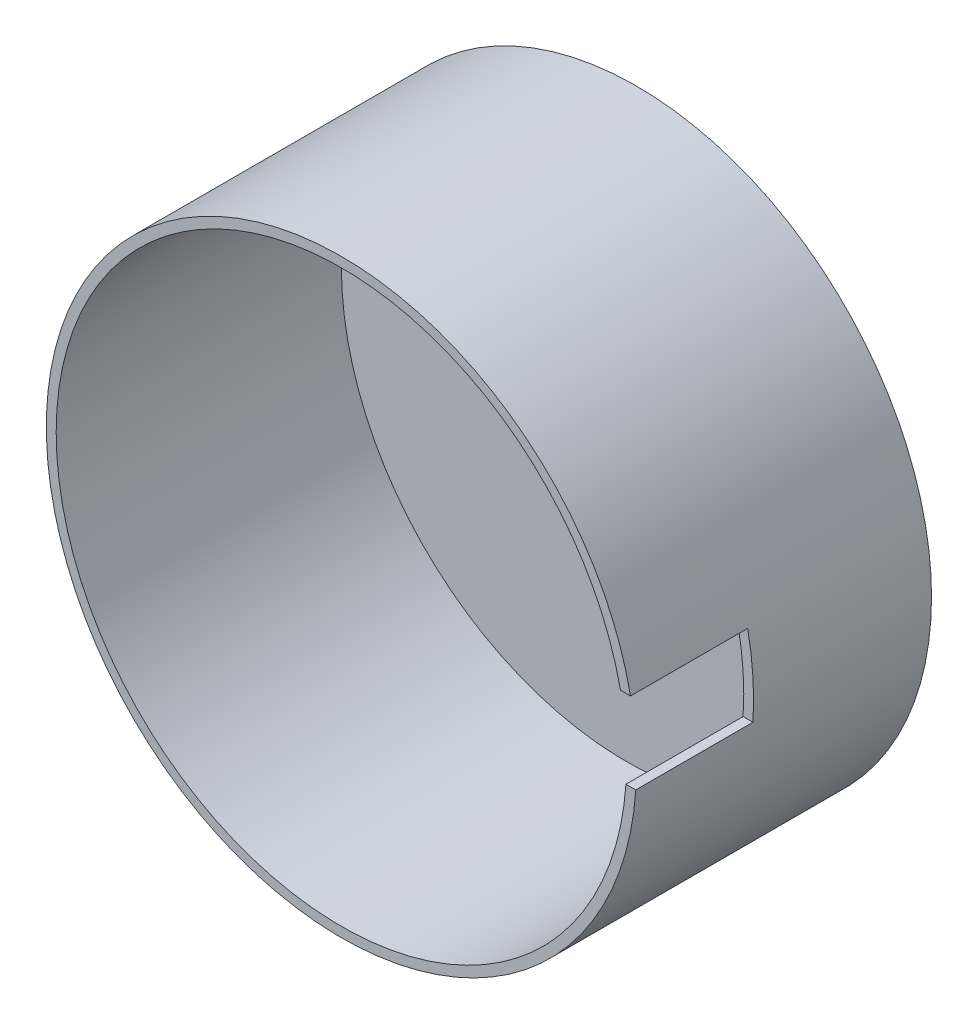
from build123d import *

# Parameters (mm, degrees)
SKETCH1_R           = 150
BOSS_EXTRUDE1_DEPTH = 150
SHELL2_T            = -5
SKETCH4_W           = 60
SKETCH4_H           = 40
CUT_EXTRUDE1_DEPTH  = 150


with BuildPart() as part:
    # Sketch1 → Boss-Extrude1 (new body)
    with BuildSketch(Plane.XY):
        Circle(SKETCH1_R)
    extrude(amount=BOSS_EXTRUDE1_DEPTH)

    # Shell2
    shell2_openings = [part.faces().sort_by_distance(p)[0] for p in [
        (0, 0, 150),
    ]]
    offset(amount=SHELL2_T, openings=shell2_openings, kind=Kind.INTERSECTION)

    # Sketch4 → Cut-Extrude1 (cut)
    with BuildSketch(Plane(origin=(0, 0, 0), x_dir=(0, 0, -1), z_dir=(1, 0, 0))):
        with Locations((-120.445229028, 9.94063613)):
            Rectangle(SKETCH4_W, SKETCH4_H)
    extrude(amount=CUT_EXTRUDE1_DEPTH, mode=Mode.SUBTRACT)


solid = part.part
